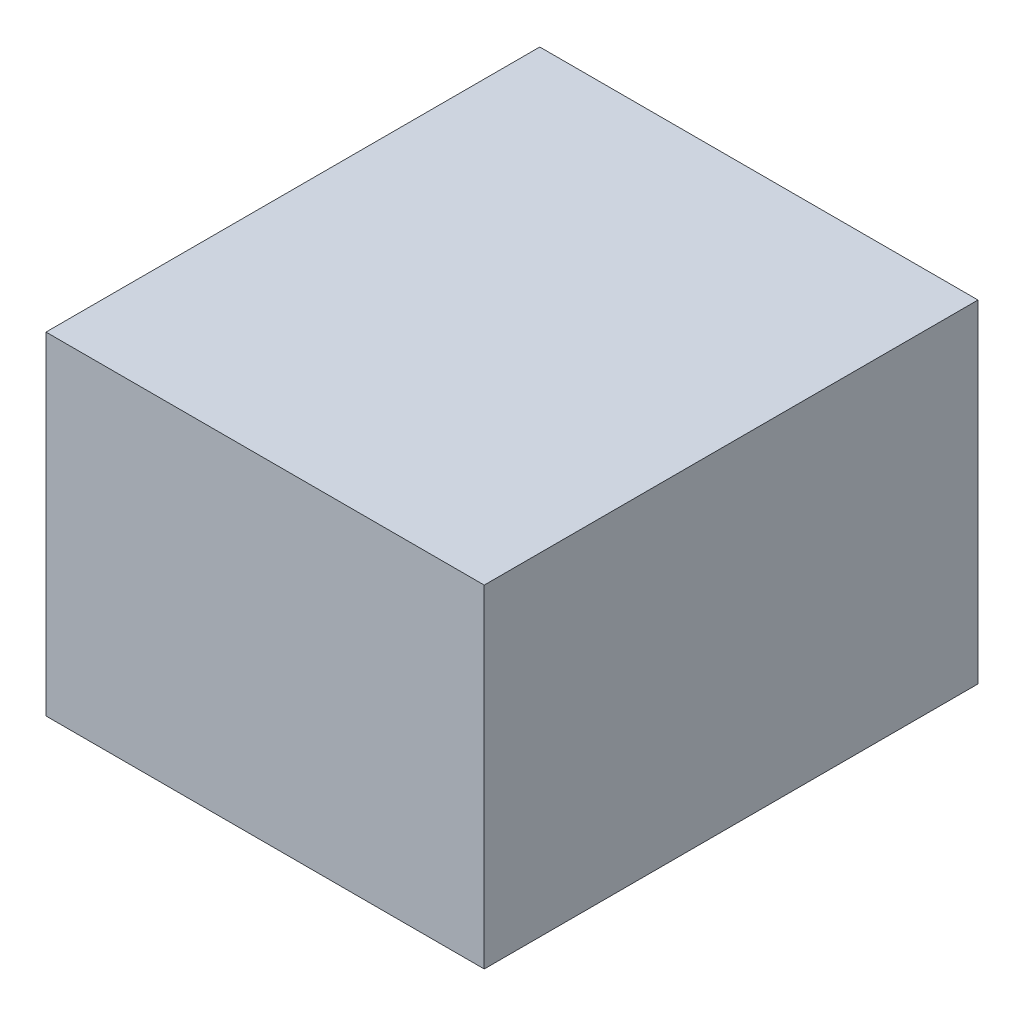
from build123d import *

# Parameters (mm, degrees)
SKETCH4_W           = 13.18
SKETCH4_H           = 14.85
BOSS_EXTRUDE2_DEPTH = 10
CUT_EXTRUDE1_DEPTH  = 5


with BuildPart() as part:
    # Sketch4 → Boss-Extrude2 (new body)
    with BuildSketch(Plane(origin=(0, 0, 0), x_dir=(1, 0, 0), z_dir=(0, 1, 0))):
        with Locations((-115.17, 78.265)):
            Rectangle(SKETCH4_W, SKETCH4_H)
    extrude(amount=BOSS_EXTRUDE2_DEPTH)

    # Sketch5 → Cut-Extrude1 (cut)
    with BuildSketch(Plane.XZ):
        with BuildLine():
            ThreePointArc((-120.17, -78.265), (-115.17, -83.265), (-110.17, -78.265))
            Line((-110.17, -78.265), (-120.17, -78.265))
        make_face()
        with BuildLine():
            Line((-120.17, -78.265), (-110.17, -78.265))
            ThreePointArc((-110.17, -78.265), (-115.17, -73.265), (-120.17, -78.265))
        make_face()
    extrude(amount=-CUT_EXTRUDE1_DEPTH, mode=Mode.SUBTRACT)


solid = part.part
